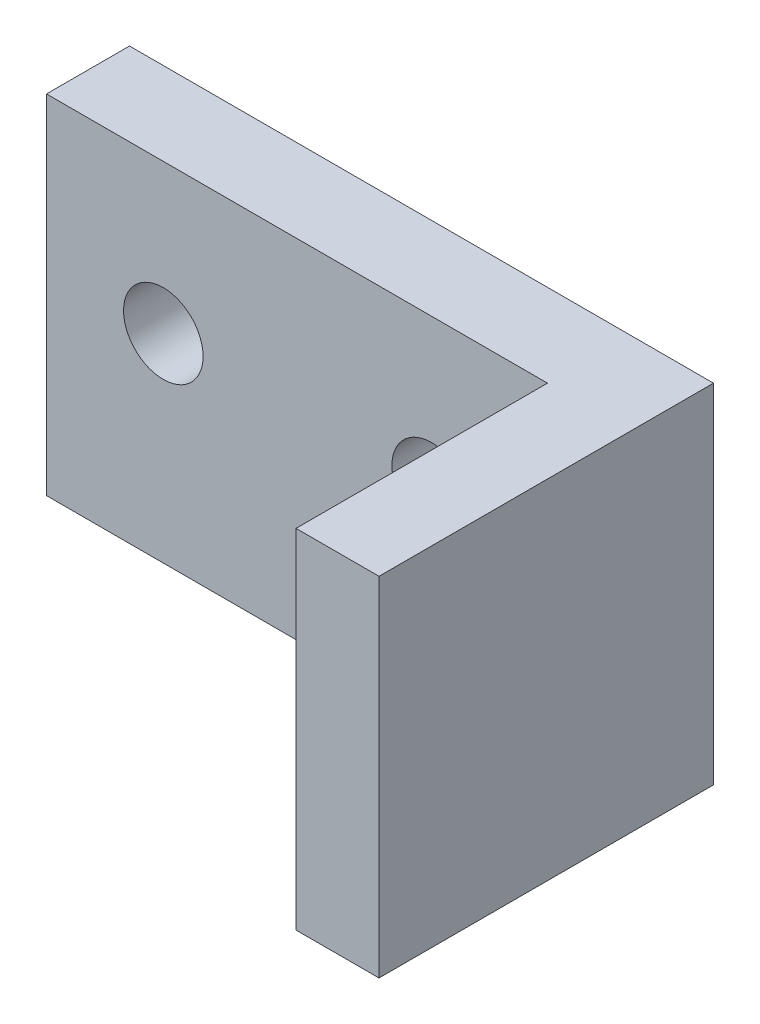
from build123d import *

# Parameters (mm, degrees)
AUFSATZ_LINEAR_START            = 170
AUFSATZ_LINEAR_AUSTRAGEN1_DEPTH = 35
SKIZZE6_R                       = 4
SCHNITT_LINEAR_AUSTRAGEN1_DEPTH = 21


with BuildPart() as part:
    # Skizze4 → Aufsatz-Linear austragen1 (new body)
    with BuildSketch(Plane(origin=(0, 0, 0), x_dir=(1, 0, 0), z_dir=(0, 1, 0)).offset(AUFSATZ_LINEAR_START)):
        Polygon((25.15, -12.65), (33.5, -12.65), (33.5, 21), (-25.25, 21), (-25.25, 12.65), (25.15, 12.65), align=None)
    extrude(amount=AUFSATZ_LINEAR_AUSTRAGEN1_DEPTH)

    # Skizze6 → Schnitt-Linear austragen1 (cut)
    with BuildSketch(Plane.XY):
        with Locations((-13.5, 190)):
            Circle(SKIZZE6_R)
        with Locations((13.5, 190)):
            Circle(SKIZZE6_R)
    extrude(amount=-SCHNITT_LINEAR_AUSTRAGEN1_DEPTH, mode=Mode.SUBTRACT)


solid = part.part
